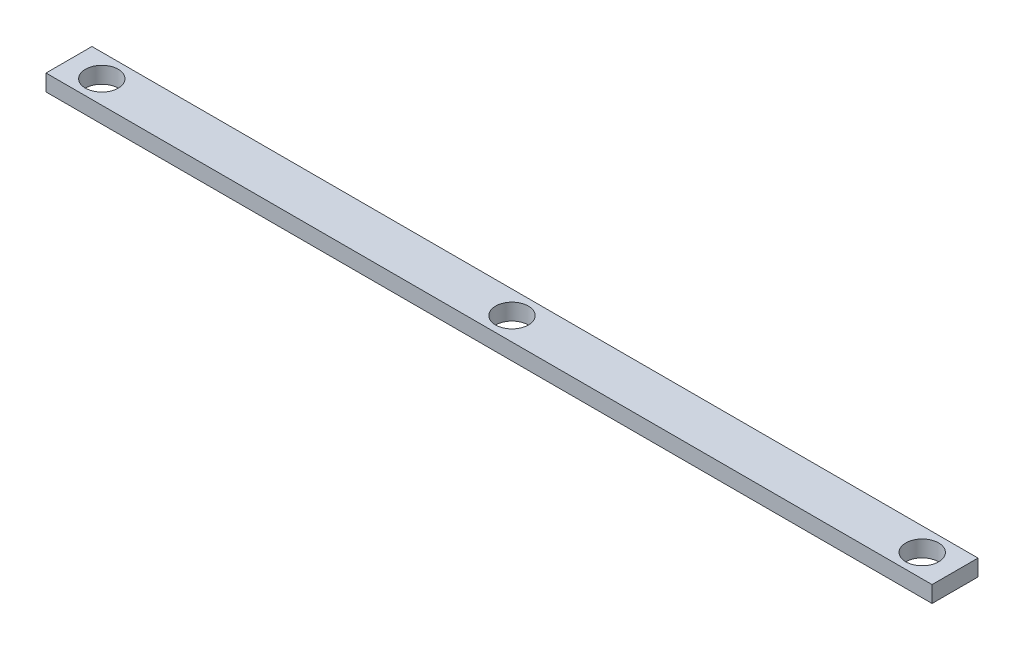
from build123d import *

# Parameters (mm, degrees)
SKETCH2_W           = 140
SKETCH2_H           = 2700
SKETCH2_R           = 50
BOSS_EXTRUDE1_DEPTH = 50


with BuildPart() as part:
    # Sketch2 → Boss-Extrude1 (new body)
    with BuildSketch(Plane.ZX):
        with Locations((22932.944645813, -11431.030459334)):
            Rectangle(SKETCH2_W, SKETCH2_H)
        with Locations((22932.944645813, -12681.030459334)):
            Circle(SKETCH2_R, mode=Mode.SUBTRACT)
        with Locations((22932.944645813, -11431.030459334)):
            Circle(SKETCH2_R, mode=Mode.SUBTRACT)
        with Locations((22932.944645813, -10181.030459334)):
            Circle(SKETCH2_R, mode=Mode.SUBTRACT)
    extrude(amount=BOSS_EXTRUDE1_DEPTH)


solid = part.part
